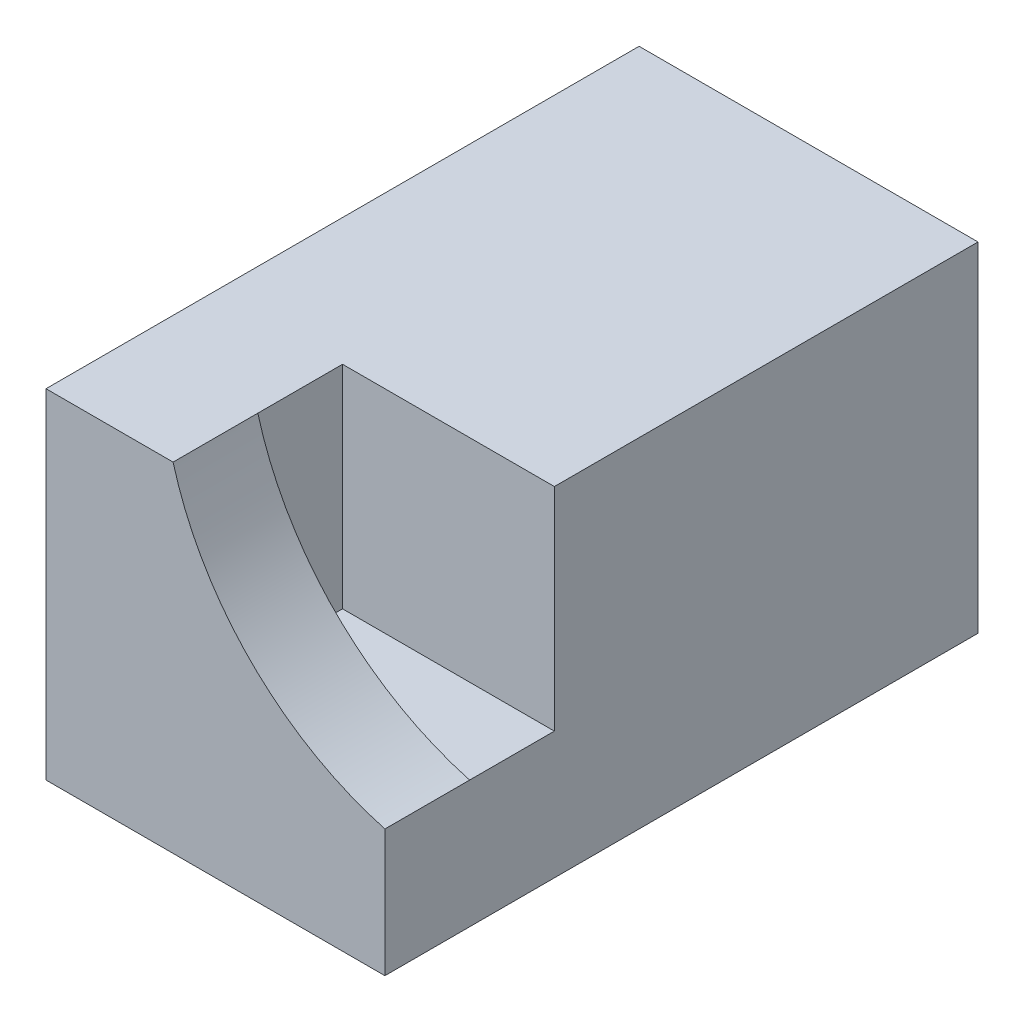
from build123d import *

# Parameters (mm, degrees)
SZKIC1_W                    = 8
SZKIC1_H                    = 8
DODANIE_WYCI_GNI_CIE1_DEPTH = 14
SZKIC3_R                    = 1.375
WYTNIJ_WYCI_GNI_CIE1_DEPTH  = 8
WYTNIJ_WYCI_GNI_CIE4_DEPTH  = 4
SZKIC7_W                    = 5
SZKIC7_H                    = 2
WYTNIJ_WYCI_GNI_CIE5_DEPTH  = 5


with BuildPart() as part:
    # Szkic1 → Dodanie-wyciągnięcie1 (new body)
    with BuildSketch(Plane.XY):
        with Locations((4, 4)):
            Rectangle(SZKIC1_W, SZKIC1_H)
    extrude(amount=DODANIE_WYCI_GNI_CIE1_DEPTH)

    # Szkic3 → Wytnij-wyciągnięcie1 (cut)
    with BuildSketch(Plane(origin=(0, 0, 0), x_dir=(-1, 0, 0), z_dir=(0, 0, -1))):
        with Locations((-4, 4)):
            Circle(SZKIC3_R)
    extrude(amount=-WYTNIJ_WYCI_GNI_CIE1_DEPTH, mode=Mode.SUBTRACT)

    # Szkic6 → Wytnij-wyciągnięcie4 (cut)
    with BuildSketch(Plane.XY.offset(14)):
        with BuildLine():
            ThreePointArc((17.051885032, 9.897788808), (8.940279558, 16.987518621), (3, 8))
            Line((3, 8), (8, 8))
            Line((8, 8), (8, 3))
            ThreePointArc((8, 3), (14.233923552, 4.207531496), (17.051885032, 9.897788808))
        make_face()
        with BuildLine():
            Line((8, 8), (3, 8))
            ThreePointArc((3, 8), (4.839078854, 4.839078854), (8, 3))
            Line((8, 3), (8, 8))
        make_face()
    extrude(amount=-WYTNIJ_WYCI_GNI_CIE4_DEPTH, mode=Mode.SUBTRACT)

    # Szkic7 → Wytnij-wyciągnięcie5 (cut)
    with BuildSketch(Plane(origin=(0, 8, 0), x_dir=(1, 0, 0), z_dir=(0, 1, 0))):
        with Locations((5.5, -11)):
            Rectangle(SZKIC7_W, SZKIC7_H)
    extrude(amount=-WYTNIJ_WYCI_GNI_CIE5_DEPTH, mode=Mode.SUBTRACT)


solid = part.part
